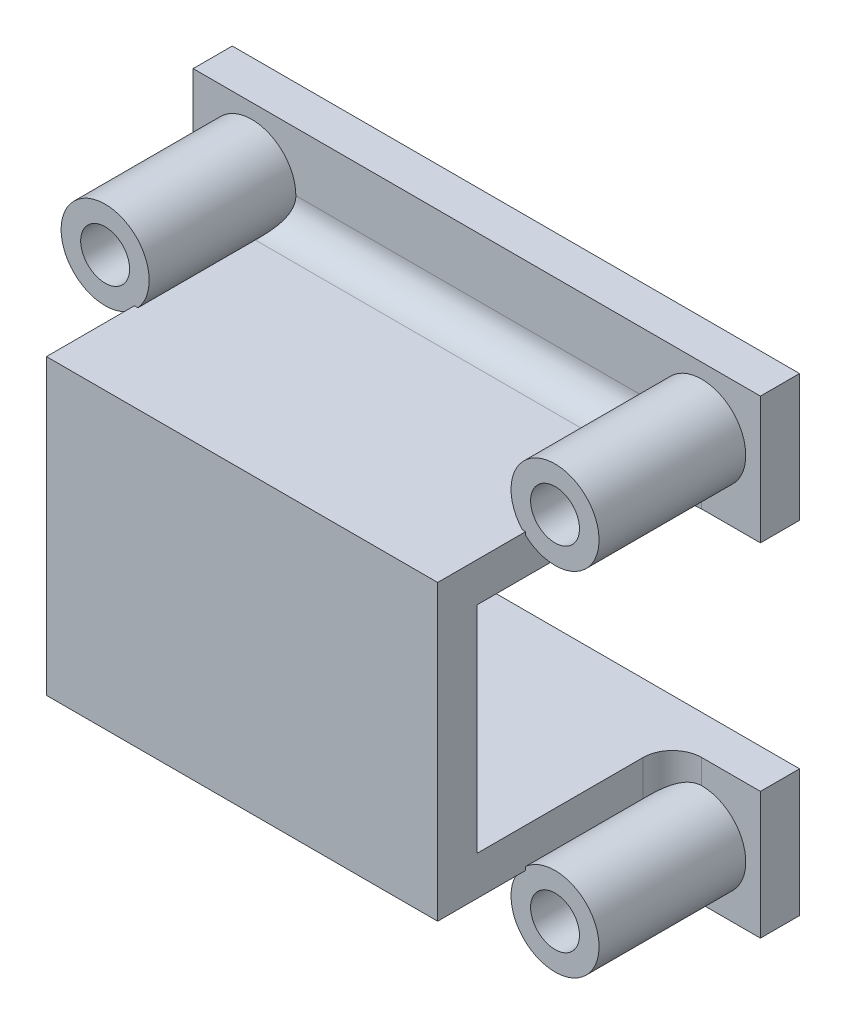
from build123d import *

# Parameters (mm, degrees)
CROQUIS1_W                   = 29
CROQUIS1_H                   = 24
SALIENTE_EXTRUIR1_DEPTH      = 2
CROQUIS2_W                   = 29
CROQUIS2_H                   = 11
CORTAR_EXTRUIR1_DEPTH        = 2
CROQUIS3_R                   = 1.25
CORTAR_EXTRUIR2_DEPTH        = 2
SIMETR_A5_COPY_1_SKETCH_R    = 1.25
SIMETR_A5_COPY_1_DEPTH       = 2
CROQUIS4_W                   = 20
CROQUIS4_H                   = 2
SALIENTE_EXTRUIR2_DEPTH      = 12
CROQUIS6_W                   = 20
CROQUIS6_H                   = 2
SALIENTE_EXTRUIR4_DEPTH      = 12
CROQUIS5_W                   = 20
CROQUIS5_H                   = 2
SALIENTE_EXTRUIR5_DEPTH      = 11
CROQUIS7_R                   = 2.25
CROQUIS7_R_2                 = 1.25
EXTRUIR_L_MINA1_DEPTH        = 7.5
SIMETR_A10_COPY_1_SKETCH_R   = 2.25
SIMETR_A10_COPY_1_SKETCH_R_2 = 1.25
SIMETR_A10_COPY_1_DEPTH      = 7.5
REDONDEO1_R                  = 1.5


with BuildPart() as part:
    # Croquis1 → Saliente-Extruir1 (new body)
    with BuildSketch(Plane.XY):
        Rectangle(CROQUIS1_W, CROQUIS1_H)
    extrude(amount=SALIENTE_EXTRUIR1_DEPTH)

    # Croquis2 → Cortar-Extruir1 (cut)
    with BuildSketch(Plane.XY.offset(2)):
        Rectangle(CROQUIS2_W, CROQUIS2_H)
    extrude(amount=-CORTAR_EXTRUIR1_DEPTH, mode=Mode.SUBTRACT)

    # Croquis3 → Cortar-Extruir2 (cut)
    with BuildSketch(Plane.XY.offset(2)):
        with Locations((-11.5, 9)):
            Circle(CROQUIS3_R)
    cortar_extruir2 = extrude(amount=-CORTAR_EXTRUIR2_DEPTH, mode=Mode.SUBTRACT)

    # Simetría2: Cortar-Extruir2 across plane
    add(cortar_extruir2.mirror(Plane(origin=(0, 0, 0), x_dir=(0, 0, 1), z_dir=(1, 0, 0))), mode=Mode.SUBTRACT)

    # Simetría5: Cortar-Extruir2 across plane
    add(cortar_extruir2.mirror(Plane.ZX), mode=Mode.SUBTRACT)

    # Simetría5 copy 1 sketch → Simetría5 copy 1 (cut)
    with BuildSketch(Plane(origin=(0, 0, 2), x_dir=(-1, 0, 0), z_dir=(0, 0, 1))):
        with Locations((-11.5, 9)):
            Circle(SIMETR_A5_COPY_1_SKETCH_R)
    extrude(amount=-SIMETR_A5_COPY_1_DEPTH, mode=Mode.SUBTRACT)

    # Croquis4 → Saliente-Extruir2 (add)
    with BuildSketch(Plane.XY.offset(2)):
        with Locations((0, 6.5)):
            Rectangle(CROQUIS4_W, CROQUIS4_H)
    extrude(amount=SALIENTE_EXTRUIR2_DEPTH)

    # Croquis6 → Saliente-Extruir4 (add)
    with BuildSketch(Plane.XY.offset(2)):
        with Locations((0, -6.5)):
            Rectangle(CROQUIS6_W, CROQUIS6_H)
    extrude(amount=SALIENTE_EXTRUIR4_DEPTH)

    # Croquis5 → Saliente-Extruir5 (add)
    with BuildSketch(Plane(origin=(0, 5.5, 0), x_dir=(-1, 0, 0), z_dir=(0, -1, 0))):
        with Locations((0, -13)):
            Rectangle(CROQUIS5_W, CROQUIS5_H)
    extrude(amount=SALIENTE_EXTRUIR5_DEPTH)

    # Croquis7 → Extruir-Lámina1 (add)
    with BuildSketch(Plane.XY.offset(2)):
        with Locations((-11.5, 9)):
            Circle(CROQUIS7_R)
        with Locations((-11.5, 9)):
            Circle(CROQUIS7_R_2, mode=Mode.SUBTRACT)
    extruir_l_mina1 = extrude(amount=EXTRUIR_L_MINA1_DEPTH)

    # Simetría8: Extruir-Lámina1 across plane
    add(extruir_l_mina1.mirror(Plane(origin=(0, 0, 0), x_dir=(0, 0, 1), z_dir=(1, 0, 0))))

    # Simetría10: Extruir-Lámina1 across plane
    add(extruir_l_mina1.mirror(Plane.ZX))

    # Simetría10 copy 1 sketch → Simetría10 copy 1 (add)
    with BuildSketch(Plane(origin=(0, 0, 2), x_dir=(-1, 0, 0), z_dir=(0, 0, 1))):
        with Locations((-11.5, 9)):
            Circle(SIMETR_A10_COPY_1_SKETCH_R)
        with Locations((-11.5, 9)):
            Circle(SIMETR_A10_COPY_1_SKETCH_R_2, mode=Mode.SUBTRACT)
    extrude(amount=SIMETR_A10_COPY_1_DEPTH)

    # Redondeo1
    redondeo1_edges = [part.edges().sort_by_distance(p)[0] for p in [
        (10, 6.411474508, 2),
        (-10, -6.411474508, 2),
        (-10, 6.411474508, 2),
        (0, 7.5, 2),
        (10, -6.411474508, 2),
        (0, -7.5, 2),
    ]]
    fillet(redondeo1_edges, radius=REDONDEO1_R)


solid = part.part
